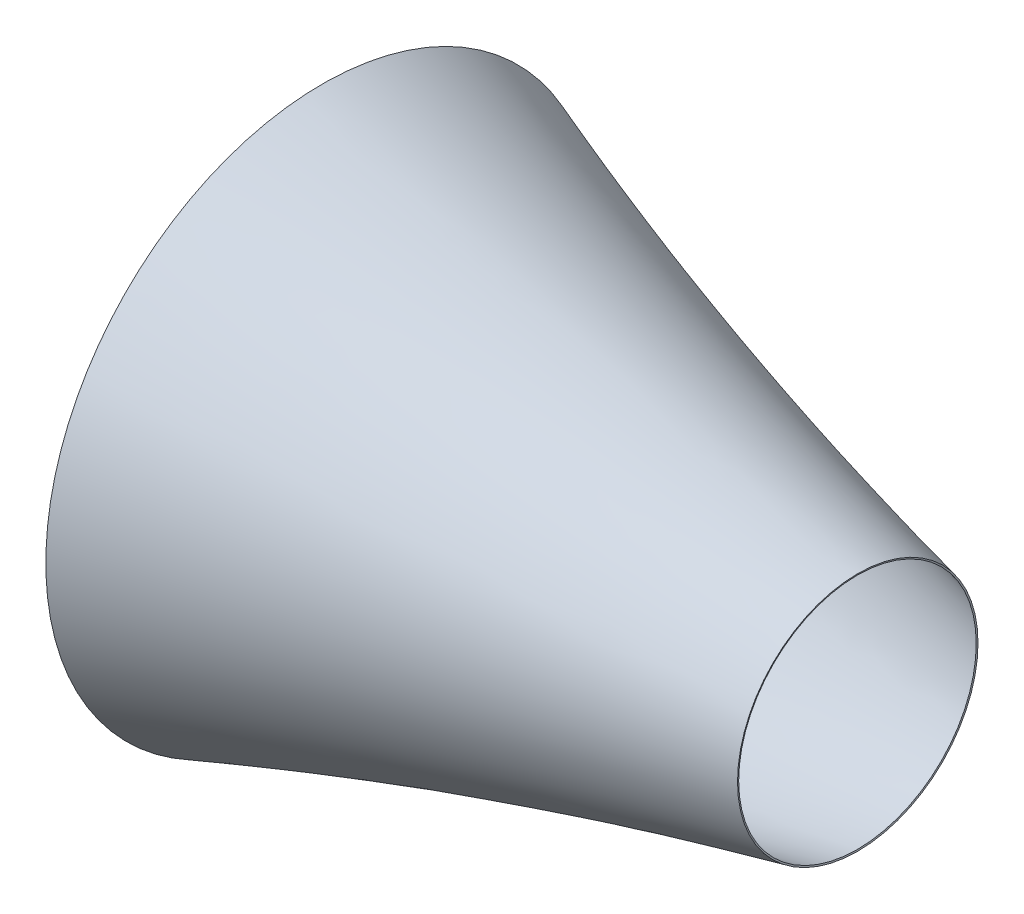
from build123d import *

# Parameters (mm, degrees)
THICKEN1_T1 = 5


with BuildPart() as body_1:
    # Surface-Revolve1: a surface, the sketch's curves turned about an axis
    with BuildLine(Plane.XY, mode=Mode.PRIVATE) as surface_revolve1_1_path:
        Line((58.164522356, 830), (33.164522356, 830))
        Line((33.164522356, 830), (25, 800))
        Line((25, 800), (0, 800))
        add(Edge.make_bspline(
            [(0, 800), (-40.64487716, 858.757553751), (0, 924.826053007)],
            knots=[0, 0, 0, 1, 1, 1], degree=2))
        add(Edge.make_bspline(
            [(0, 924.826053007), (882.609063012, 601.254612797), (1800, 400)],
            knots=[0, 0, 0, 1, 1, 1], degree=2))
    surface_revolve1_1 = Shell.revolve(surface_revolve1_1_path.wire(), 360, Axis((0, 0, 0), (1, 0, 0)))
    add(Solid.thicken(surface_revolve1_1, THICKEN1_T1))


solid = body_1.part
